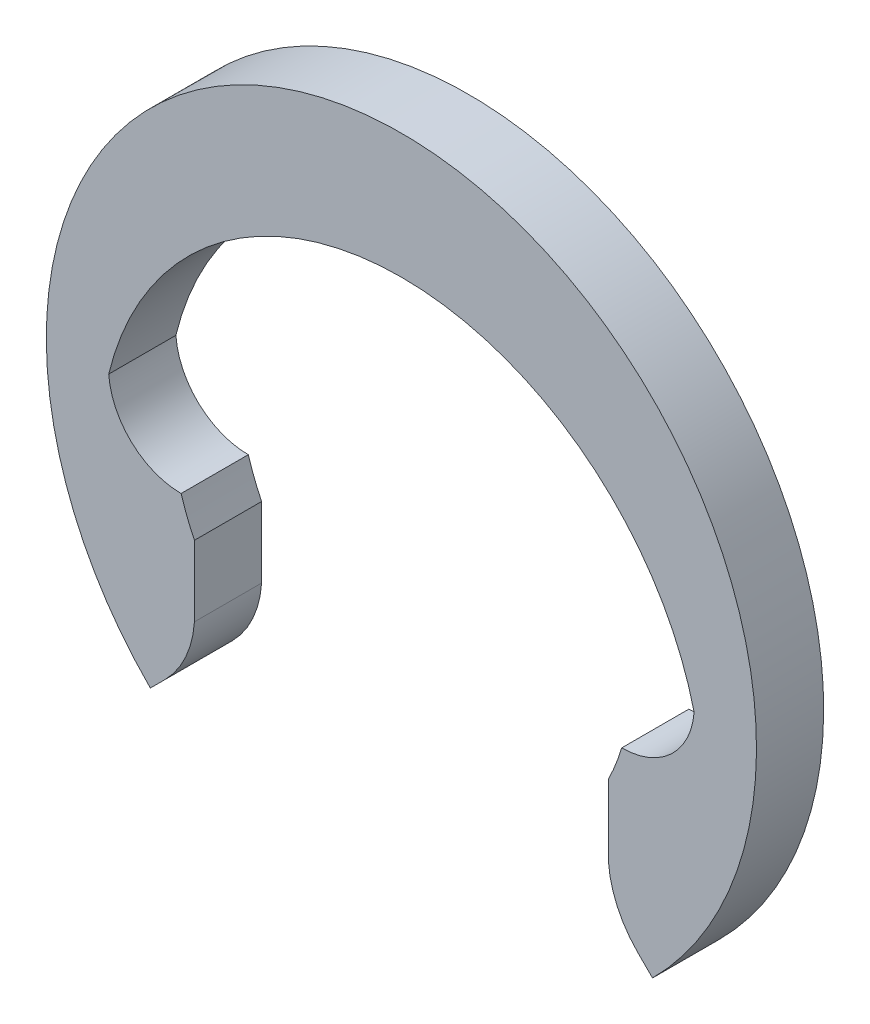
from build123d import *

# Parameters (mm, degrees)
BOSS_EXTRUDE1_DEPTH = 0.7


with BuildPart() as part:
    # Sketch2 → Boss-Extrude1 (new body)
    with BuildSketch(Plane.XY):
        with BuildLine():
            Line((-2.156675683, -1.78877445), (-2.156675683, -1.420873217))
            Line((-2.156675683, -1.420873217), (-2.156675683, -1.052971984))
            ThreePointArc((-2.156675683, -1.052971984), (-2.233146653, -0.879236046), (-2.295648057, -0.7))
            ThreePointArc((-2.295648057, -0.7), (-2.810198067, -0.498040533), (-3.05, 0))
            ThreePointArc((-3.05, 0), (0, 2.4), (3.05, 0))
            ThreePointArc((3.05, 0), (2.810198067, -0.498040533), (2.295648057, -0.7))
            ThreePointArc((2.295648057, -0.7), (2.233146653, -0.879236046), (2.156675683, -1.052971984))
            Line((2.156675683, -1.052971984), (2.156675683, -1.420873217))
            Line((2.156675683, -1.420873217), (2.156675683, -1.78877445))
            ThreePointArc((2.156675683, -1.78877445), (2.248723901, -2.15372226), (2.463088621, -2.463088621))
            Line((2.463088621, -2.463088621), (2.61629509, -2.61629509))
            ThreePointArc((2.61629509, -2.61629509), (0, 3.7), (-2.61629509, -2.61629509))
            Line((-2.61629509, -2.61629509), (-2.463088621, -2.463088621))
            ThreePointArc((-2.463088621, -2.463088621), (-2.248723901, -2.15372226), (-2.156675683, -1.78877445))
        make_face()
    extrude(amount=BOSS_EXTRUDE1_DEPTH)


solid = part.part
